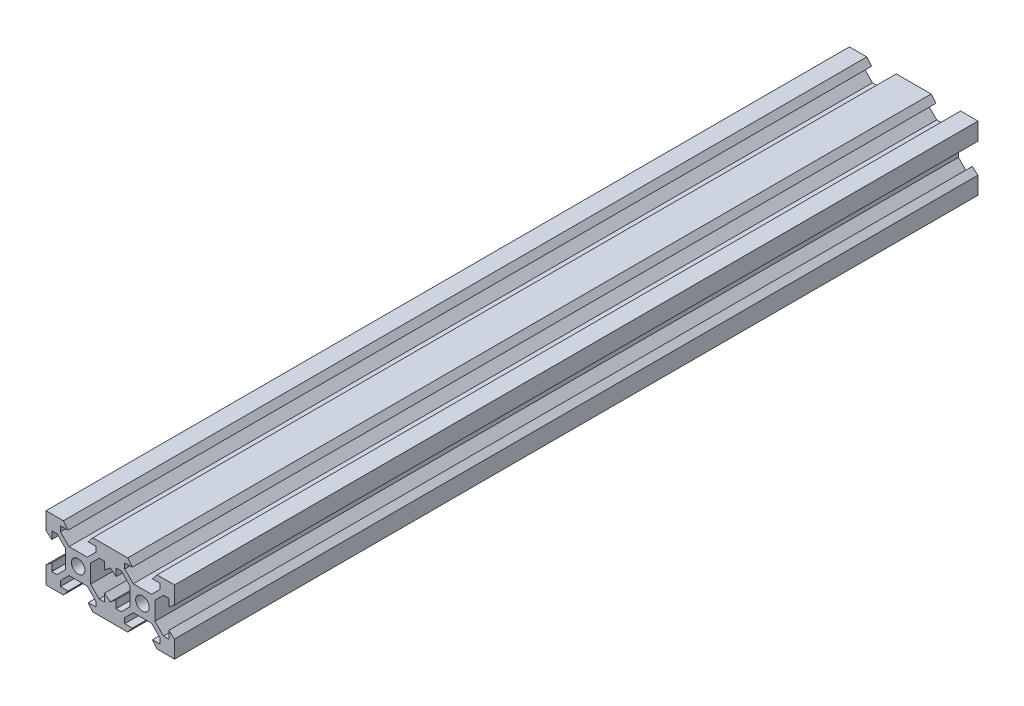
from build123d import *

# Parameters (mm, degrees)
BOSS_EXTRUDE1_DEPTH = 250


with BuildPart() as part:
    # Sketch2 → Boss-Extrude1 (new body)
    with BuildSketch(Plane.XY):
        with BuildLine():
            Line((2.839339828, 3.9), (0, 3.9))
            Line((0, 3.9), (0, 2.1))
            ThreePointArc((0, 2.1), (1.48492424, 1.48492424), (2.1, 0))
            ThreePointArc((2.1, 0), (0, -2.1), (-2.1, 0))
            Line((-2.1, 0), (-3.9, 0))
            Line((-3.9, 0), (-3.9, -2.839339828))
            Line((-3.9, -2.839339828), (-6.560660172, -5.5))
            Line((-6.560660172, -5.5), (-8.2, -5.5))
            Line((-8.2, -5.5), (-8.2, -3.125))
            Line((-8.2, -3.125), (-10, -4.58))
            Line((-10, -4.58), (-10, -10))
            Line((-10, -10), (-4.58, -10))
            Line((-4.58, -10), (-3.125, -8.2))
            Line((-3.125, -8.2), (-5.5, -8.2))
            Line((-5.5, -8.2), (-5.5, -6.560660172))
            Line((-5.5, -6.560660172), (-2.839339828, -3.9))
            Line((-2.839339828, -3.9), (0, -3.9))
            Line((0, -3.9), (2.839339828, -3.9))
            Line((2.839339828, -3.9), (5.5, -6.560660172))
            Line((5.5, -6.560660172), (5.5, -8.2))
            Line((5.5, -8.2), (3.125, -8.2))
            Line((3.125, -8.2), (4.58, -10))
            Line((4.58, -10), (10, -10))
            Line((10, -10), (10, -4.58))
            Line((10, -4.58), (8.2, -3.125))
            Line((8.2, -3.125), (8.2, -5.5))
            Line((8.2, -5.5), (6.560660172, -5.5))
            Line((6.560660172, -5.5), (3.9, -2.839339828))
            Line((3.9, -2.839339828), (3.9, 0))
            Line((3.9, 0), (3.9, 2.839339828))
            Line((3.9, 2.839339828), (6.560660172, 5.5))
            Line((6.560660172, 5.5), (8.2, 5.5))
            Line((8.2, 5.5), (8.2, 3.125))
            Line((8.2, 3.125), (10, 4.58))
            Line((10, 4.58), (10, 10))
            Line((10, 10), (4.58, 10))
            Line((4.58, 10), (3.125, 8.2))
            Line((3.125, 8.2), (5.5, 8.2))
            Line((5.5, 8.2), (5.5, 6.560660172))
            Line((5.5, 6.560660172), (2.839339828, 3.9))
        make_face()
        with BuildLine():
            Line((-1.48492424, 1.48492424), (-10, 10))
            Line((-10, 10), (-10, 4.58))
            Line((-10, 4.58), (-8.2, 3.125))
            Line((-8.2, 3.125), (-8.2, 5.5))
            Line((-8.2, 5.5), (-6.560660172, 5.5))
            Line((-6.560660172, 5.5), (-3.9, 2.839339828))
            Line((-3.9, 2.839339828), (-3.9, 0))
            Line((-3.9, 0), (-2.1, 0))
            ThreePointArc((-2.1, 0), (-1.940147018, 0.803635208), (-1.48492424, 1.48492424))
        make_face()
        with BuildLine():
            Line((-5.5, 6.560660172), (-5.5, 8.2))
            Line((-5.5, 8.2), (-3.125, 8.2))
            Line((-3.125, 8.2), (-4.58, 10))
            Line((-4.58, 10), (-10, 10))
            Line((-10, 10), (-1.48492424, 1.48492424))
            ThreePointArc((-1.48492424, 1.48492424), (-0.803635208, 1.940147018), (0, 2.1))
            Line((0, 2.1), (0, 3.9))
            Line((0, 3.9), (-2.839339828, 3.9))
            Line((-2.839339828, 3.9), (-5.5, 6.560660172))
        make_face()
    boss_extrude1 = extrude(amount=BOSS_EXTRUDE1_DEPTH)

    # Mirror1: Boss-Extrude1 across plane
    add(boss_extrude1.mirror(Plane(origin=(10, 0, 250), x_dir=(0, 0, 1), z_dir=(1, 0, 0))))


solid = part.part
